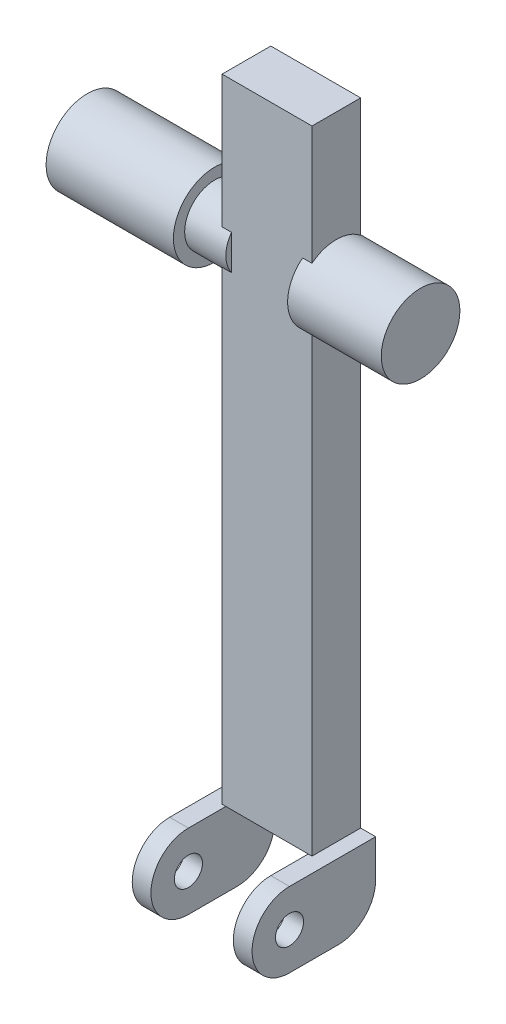
from build123d import *

# Parameters (mm, degrees)
SKETCH3_R                = 16
BOSS_EXTRUDE1_DEPTH      = 22
SKETCH4_R                = 22
BOSS_EXTRUDE2_DEPTH      = 68
SKETCH2_R                = 21
BOSS_EXTRUDE3_DEPTH      = 50
SKETCH1_W                = 48
SKETCH1_H                = 26
BOSS_EXTRUDE5_DEPTH      = 80
BOSS_EXTRUDE5_DEPTH_BACK = 257.72
BOSS_EXTRUDE7_START      = -2
BOSS_EXTRUDE7_DEPTH      = 10
CUT_EXTRUDE4_START       = -10
SKETCH10_R               = 7.5
CUT_EXTRUDE4_DEPTH       = 10


with BuildPart() as part:
    # Sketch3 → Boss-Extrude1 (new body)
    with BuildSketch(Plane(origin=(-19, 0, 0), x_dir=(0, 0, -1), z_dir=(1, 0, 0))):
        Circle(SKETCH3_R)
    extrude(amount=-BOSS_EXTRUDE1_DEPTH)

    # Sketch4 → Boss-Extrude2 (add)
    with BuildSketch(Plane.ZY.offset(41)):
        Circle(SKETCH4_R)
    extrude(amount=BOSS_EXTRUDE2_DEPTH)



with BuildPart() as body_2:
    # Sketch2 → Boss-Extrude3 (new body)
    with BuildSketch(Plane(origin=(19, 0, 0), x_dir=(0, 0, -1), z_dir=(1, 0, 0))):
        Circle(SKETCH2_R)
    extrude(amount=BOSS_EXTRUDE3_DEPTH)


with BuildPart() as part_1:
    add(part.part)

    add(body_2.part)  # Boss-Extrude5 merges body 2
    # Sketch1 → Boss-Extrude5 (add, two sides)
    with BuildSketch(Plane(origin=(0, 0, 0), x_dir=(1, 0, 0), z_dir=(0, 1, 0))) as boss_extrude5_sk:
        Rectangle(SKETCH1_W, SKETCH1_H)
    extrude(amount=BOSS_EXTRUDE5_DEPTH)
    extrude(boss_extrude5_sk.sketch, amount=-BOSS_EXTRUDE5_DEPTH_BACK)


with BuildPart() as body_2_2:
    # Sketch5 → Boss-Extrude7 (new body)
    with BuildSketch(Plane(origin=(24, 0, 0), x_dir=(0, 0, -1), z_dir=(1, 0, 0)).offset(BOSS_EXTRUDE7_START)):
        with BuildLine():
            Line((13, -257.72), (-33, -257.72))
            ThreePointArc((-33, -257.72), (-53, -277.72), (-33, -297.72))
            Line((-33, -297.72), (-7, -297.72))
            ThreePointArc((-7, -297.72), (7.142135624, -291.862135624), (13, -277.72))
            Line((13, -277.72), (13, -257.72))
        make_face()
    boss_extrude7 = extrude(amount=BOSS_EXTRUDE7_DEPTH)

    # Sketch10 → Cut-Extrude4 (cut)
    with BuildSketch(Plane.ZY.offset(-22).offset(CUT_EXTRUDE4_START)):
        with Locations((33, -277.72)):
            Circle(SKETCH10_R)
    cut_extrude4 = extrude(amount=CUT_EXTRUDE4_DEPTH, mode=Mode.SUBTRACT)


with BuildPart() as part_2:
    add(part_1.part)

    # Mirror26: Boss-Extrude7, Cut-Extrude4 across plane
    add(boss_extrude7.mirror(Plane(origin=(0, 0, 0), x_dir=(0, 0, 1), z_dir=(1, 0, 0))))
    add(cut_extrude4.mirror(Plane(origin=(0, 0, 0), x_dir=(0, 0, 1), z_dir=(1, 0, 0))), mode=Mode.SUBTRACT)


solid = Compound([body_2_2.part, part_2.part])
